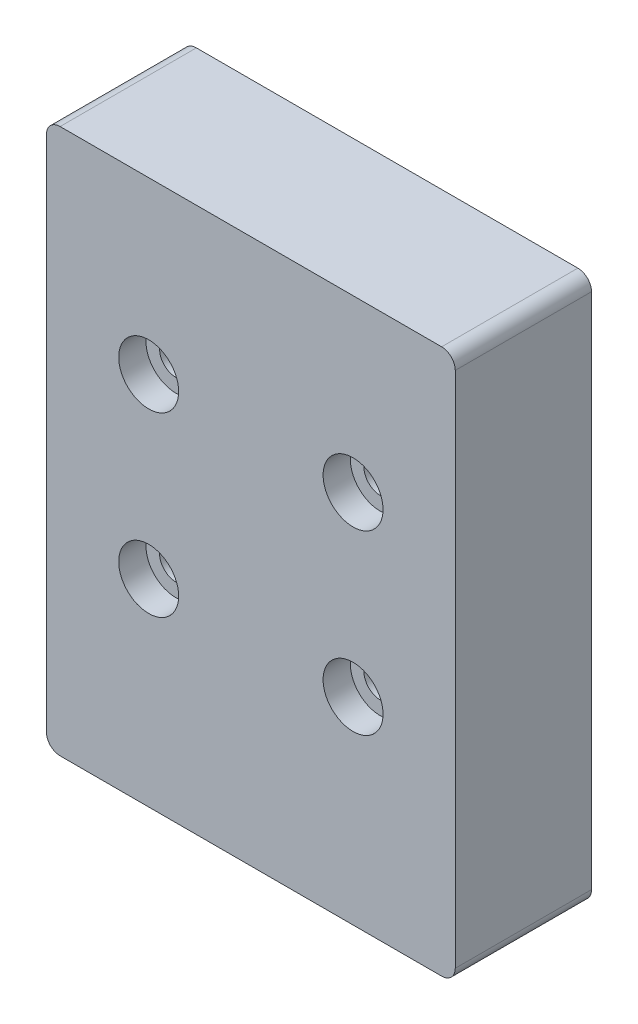
from build123d import *

# Parameters (mm, degrees)
SKETCH1_W                              = 30
SKETCH1_H                              = 40
BODY_DEPTH                             = 5
CBORE_FOR_M2_HEX_HEAD_BOLT2_AT_2_COUNT = 2
CBORE_FOR_M2_HEX_HEAD_BOLT2_AT_2_PITCH = 15
LPATTERN1_COUNT                        = 2
LPATTERN1_PITCH                        = 13
FILLET1_R                              = 1


with BuildPart() as part:
    # Sketch1 → Body (new body, symmetric)
    with BuildSketch(Plane.XY):
        Rectangle(SKETCH1_W, SKETCH1_H)
    extrude(amount=BODY_DEPTH, both=True)

    # Sketch6 → CBORE for M2 Hex Head Bolt2 (revolve, cut)
    with BuildSketch(Plane(origin=(-7.5, 7.5, 5), x_dir=(0, -1, 0), z_dir=(1, 0, 0))):
        Polygon((0, 0), (0, 10.721032743), (1.2, 10), (1.2, 2), (2.2, 2), (2.2, 0), align=None)
    cbore_for_m2_hex_head_bolt2 = revolve(axis=Axis((-7.5, 7.5, 11.35), (0, 0, -1)), mode=Mode.SUBTRACT)

    # CBORE for M2 Hex Head Bolt2 at 2: CBORE for M2 Hex Head Bolt2 ×2
    with Locations(*[(i * CBORE_FOR_M2_HEX_HEAD_BOLT2_AT_2_PITCH, 0, 0) for i in range(1, CBORE_FOR_M2_HEX_HEAD_BOLT2_AT_2_COUNT)]):
        add(cbore_for_m2_hex_head_bolt2, mode=Mode.SUBTRACT)

    # LPattern1: CBORE for M2 Hex Head Bolt2 ×2
    with Locations(*[(0, -i * LPATTERN1_PITCH, 0) for i in range(1, LPATTERN1_COUNT)]):
        add(cbore_for_m2_hex_head_bolt2, mode=Mode.SUBTRACT)

    # LPattern1 copy 1 sketch → LPattern1 copy 1 (revolve, cut)
    with BuildSketch(Plane(origin=(7.5, -5.5, 5), x_dir=(0, -1, 0), z_dir=(1, 0, 0))):
        Polygon((0, 0), (0, 10.721032743), (1.2, 10), (1.2, 2), (2.2, 2), (2.2, 0), align=None)
    revolve(axis=Axis((7.5, -5.5, 11.35), (0, 0, -1)), mode=Mode.SUBTRACT)

    # Fillet1
    fillet1_edges = [part.edges().sort_by_distance(p)[0] for p in [
        (15, -20, 0),
        (-15, -20, 0),
        (-15, 20, 0),
        (15, 20, 0),
    ]]
    fillet(fillet1_edges, radius=FILLET1_R)


solid = part.part
